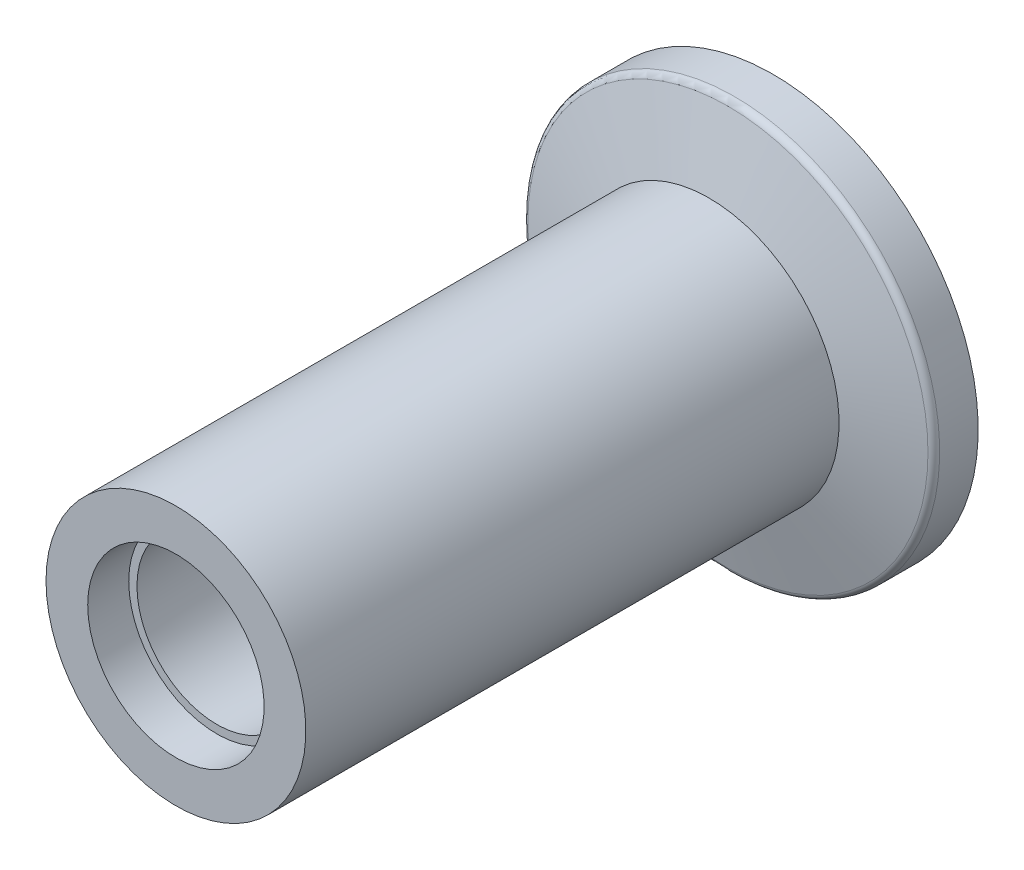
from build123d import *


with BuildPart() as part:
    # Sketch1 → Revolve1 (revolve)
    with BuildSketch(Plane.XZ):
        with BuildLine():
            Line((9.7, 2.502), (9.7, 12.002))
            Line((9.7, 12.002), (9.7, 41.490552817))
            Line((9.7, 41.490552817), (6.65, 41.490552817))
            Line((6.65, 41.490552817), (6.65, 38.490552817))
            Line((6.65, 38.490552817), (6.05, 38.490552817))
            Line((6.05, 38.490552817), (8.05, 0.328279442))
            Line((8.05, 0.328279442), (9.2, 0.328279442))
            Line((9.2, 0.328279442), (9.2, -2.171720558))
            Line((9.2, -2.171720558), (15.2, -2.171720558))
            Line((15.2, -2.171720558), (15.2, 0.644615948))
            ThreePointArc((15.2, 0.644615948), (15.09667667, 0.948996662), (14.829409523, 1.127578861))
            Line((14.829409523, 1.127578861), (9.7, 2.502))
        make_face()
    revolve(axis=Axis((0.2, 0, 11.872), (0, 0, -1)))


solid = part.part
